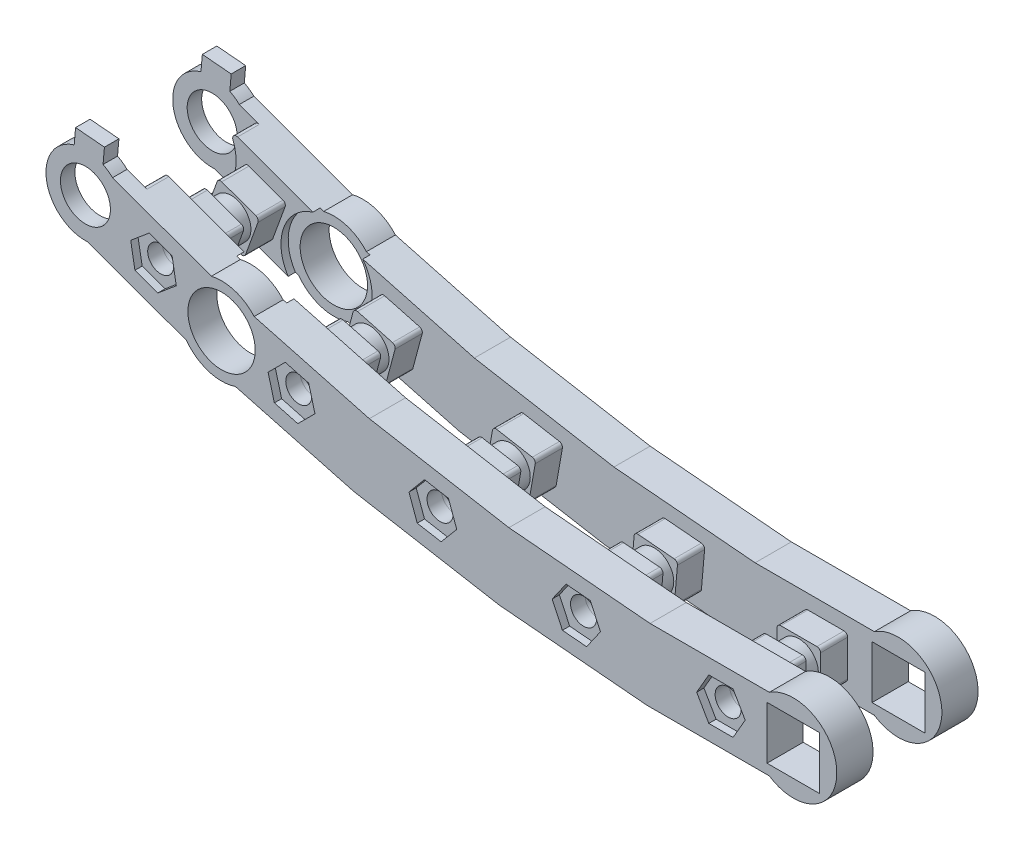
from build123d import *

# Parameters (mm, degrees)
SKETCH_1_R               = 1.8
SKETCH_1_R_2             = 3.45
SKETCH_1_W               = 7.28
SKETCH_1_H               = 7.28
EXTRUDE_1_DEPTH          = 2
SKETCH_2_R               = 1.8
SKETCH_2_W               = 7.28
SKETCH_2_H               = 7.28
EXTRUDE_2_DEPTH          = 3
EXTRUDE_3_DEPTH          = 2
SKETCH_4_R               = 1.8
SKETCH_4_R_2             = 3.45
SKETCH_4_W               = 7.28
SKETCH_4_H               = 7.28
EXTRUDE_4_DEPTH          = 2
SKETCH_5_R               = 1.8
SKETCH_5_W               = 7.28
SKETCH_5_H               = 7.28
EXTRUDE_5_DEPTH          = 3
EXTRUDE_6_DEPTH          = 2
SKETCH_7_W               = 6.2
SKETCH_7_H               = 6.2
CUT_EXTRUDE_1_DEPTH      = 2
SKETCH_8_W               = 6
SKETCH_8_H               = 6
SKETCH_8_R               = 1.8
EXTRUDE_7_DEPTH          = 11.5
SKETCH_9_R               = 2.7
SKETCH_9_W               = 6
SKETCH_9_H               = 6
CUT_EXTRUDE_2_DEPTH      = 1
CUT_EXTRUDE_2_DEPTH_BACK = 1
CUT_EXTRUDE_3_DEPTH      = 1
SKETCH_11_R              = 3.25
CUT_EXTRUDE_4_DEPTH      = 1.5
SKETCH_12_R              = 4.65
CUT_EXTRUDE_5_DEPTH      = 20.5
SKETCH_13_R              = 6.3
CUT_EXTRUDE_6_DEPTH      = 1
SKETCH_14_R              = 6.3
CUT_EXTRUDE_7_DEPTH      = 1
EXTRUDE_8_DEPTH          = 4
EXTRUDE_9_DEPTH          = 4
FILLET_1_R               = 0.5


with BuildPart() as part:
    # ｽｹｯﾁ1 → ﾎﾞｽ - 押し出し1 (new body)
    with BuildSketch(Plane.XY):
        with BuildLine():
            Line((-93.984570453, 21.189646103), (-77.433604161, 15.165587024))
            Line((-77.433604161, 15.165587024), (-58.536819958, 10.102208957))
            Line((-58.536819958, 10.102208957), (-39.270641249, 6.705061836))
            Line((-39.270641249, 6.705061836), (-19.781695285, 5))
            Line((-19.781695285, 5), (-3.31662479, 5))
            ThreePointArc((-3.31662479, 5), (6, 0), (-3.31662479, -5))
            Line((-3.31662479, -5), (-20.218304715, -5))
            Line((-20.218304715, -5), (-40.577146675, -3.218832126))
            Line((-40.577146675, -3.218832126), (-60.703278086, 0.329947859))
            Line((-60.703278086, 0.329947859), (-80.443526935, 5.619331597))
            Line((-80.443526935, 5.619331597), (-97.404771886, 11.792719895))
            ThreePointArc((-97.404771886, 11.792719895), (-102.853742747, 19.096871958), (-93.984570453, 21.189646103))
        make_face()
        with Locations((-10, 0)):
            Circle(SKETCH_1_R, mode=Mode.SUBTRACT)
        with Locations((-29.961946981, 0.871557427)):
            Circle(SKETCH_1_R, mode=Mode.SUBTRACT)
        with Locations((-49.771971492, 3.479596632)):
            Circle(SKETCH_1_R, mode=Mode.SUBTRACT)
        with Locations((-69.279307285, 7.804268859)):
            Circle(SKETCH_1_R, mode=Mode.SUBTRACT)
        with Locations((-88.335491756, 13.812660744)):
            Circle(SKETCH_1_R, mode=Mode.SUBTRACT)
        with Locations((-97.732417964, 17.232862177)):
            Circle(SKETCH_1_R_2, mode=Mode.SUBTRACT)
        Rectangle(SKETCH_1_W, SKETCH_1_H, mode=Mode.SUBTRACT)
    extrude(amount=EXTRUDE_1_DEPTH)

    # ｽｹｯﾁ2 → ﾎﾞｽ - 押し出し2 (add)
    with BuildSketch(Plane(origin=(0, 0, 0), x_dir=(-1, 0, 0), z_dir=(0, 0, -1))):
        with BuildLine():
            Line((91.23172777, 20.187693307), (77.433604161, 15.165587024))
            Line((77.433604161, 15.165587024), (58.536819958, 10.102208957))
            Line((58.536819958, 10.102208957), (39.270641249, 6.705061836))
            Line((39.270641249, 6.705061836), (19.781695285, 5))
            Line((19.781695285, 5), (3.31662479, 5))
            ThreePointArc((3.31662479, 5), (-6, 0), (3.31662479, -5))
            Line((3.31662479, -5), (20.218304715, -5))
            Line((20.218304715, -5), (40.577146675, -3.218832126))
            Line((40.577146675, -3.218832126), (60.703278086, 0.329947859))
            Line((60.703278086, 0.329947859), (80.443526935, 5.619331597))
            Line((80.443526935, 5.619331597), (94.651929203, 10.790767099))
            ThreePointArc((94.651929203, 10.790767099), (94.979522995, 11.223274587), (94.719999928, 11.699749348))
            ThreePointArc((94.719999928, 11.699749348), (91.812354453, 15.078135274), (91.868155498, 19.535127524))
            ThreePointArc((91.868155498, 19.535127524), (91.760689628, 20.066946579), (91.23172777, 20.187693307))
        make_face()
        with Locations((29.961946981, 0.871557427)):
            Circle(SKETCH_2_R, mode=Mode.SUBTRACT)
        with Locations((10, 0)):
            Circle(SKETCH_2_R, mode=Mode.SUBTRACT)
        with Locations((88.335491756, 13.812660744)):
            Circle(SKETCH_2_R, mode=Mode.SUBTRACT)
        with Locations((69.279307285, 7.804268859)):
            Circle(SKETCH_2_R, mode=Mode.SUBTRACT)
        with Locations((49.771971492, 3.479596632)):
            Circle(SKETCH_2_R, mode=Mode.SUBTRACT)
        Rectangle(SKETCH_2_W, SKETCH_2_H, mode=Mode.SUBTRACT)
    extrude(amount=EXTRUDE_2_DEPTH)

    # ｽｹｯﾁ3 → ﾎﾞｽ - 押し出し3 (add)
    with BuildSketch(Plane.XY.offset(2)):
        Polygon((-95.108149432, 24.280962253), (-95.421910106, 20.694661339), (-99.406688899, 21.04328431), (-99.092928225, 24.629585224), align=None)
    extrude(amount=-EXTRUDE_3_DEPTH)

    # ｽｹｯﾁ7 → ｶｯﾄ - 押し出し1 (cut)
    with BuildSketch(Plane(origin=(0, 0, -3), x_dir=(-1, 0, 0), z_dir=(0, 0, -1))):
        Polygon((27.143926219, -2.486828939), (26.603560614, 3.689578189), (32.779967742, 4.229943794), (33.320333348, -1.946463334), align=None)
        with Locations((10, 0)):
            Rectangle(SKETCH_7_W, SKETCH_7_H)
        Polygon((47.257376808, -0.111616753), (46.180758107, 5.994191315), (52.286566176, 7.070810017), (53.363184877, 0.965001948), align=None)
        Polygon((67.087276263, 4.007559758), (65.482598184, 9.996299881), (71.471338307, 11.600977961), (73.076016386, 5.612237838), align=None)
        Polygon((90.188276436, 17.785970312), (84.362182187, 15.665445424), (86.482707076, 9.839351175), (92.308801324, 11.959876063), align=None)
    extrude(amount=-CUT_EXTRUDE_1_DEPTH, mode=Mode.SUBTRACT)

    # ｽｹｯﾁ10 → ｶｯﾄ - 押し出し3 (cut)
    with BuildSketch(Plane.XY.offset(2)):
        Polygon((-11.674315781, 2.9), (-13.348631561, 0), (-11.674315781, -2.9), (-8.325684219, -2.9), (-6.651368439, 0), (-8.325684219, 2.9), align=None)
        Polygon((-31.882643139, -1.871480962), (-28.546754131, -2.163333432), (-26.626057974, 0.579704957), (-28.041250823, 3.614595816), (-31.377139831, 3.906448287), (-33.297835988, 1.163409898), align=None)
        Polygon((-51.924430369, 0.914396032), (-48.626672045, 0.332912264), (-46.474213168, 2.898112863), (-47.619512615, 6.044797231), (-50.917270938, 6.626281), (-53.069729816, 4.0610804), align=None)
        Polygon((-71.64714737, 5.436428775), (-68.412617662, 4.569739152), (-66.044777577, 6.937579236), (-66.9114672, 10.172108944), (-70.145996908, 11.038798567), (-72.513836993, 8.670958482), align=None)
        Polygon((-90.900692355, 11.660201867), (-87.754007987, 10.51490242), (-85.188807388, 12.667361297), (-85.770291156, 15.965119621), (-88.916975524, 17.110419067), (-91.482176124, 14.95796019), align=None)
    extrude(amount=-CUT_EXTRUDE_3_DEPTH, mode=Mode.SUBTRACT)


with BuildPart() as body_2:
    # ｽｹｯﾁ4 → ﾎﾞｽ - 押し出し4 (new body)
    with BuildSketch(Plane.XY.offset(-17.5)):
        with BuildLine():
            Line((-77.433604161, 15.165587024), (-93.984570453, 21.189646103))
            ThreePointArc((-93.984570453, 21.189646103), (-102.853742747, 19.096871958), (-97.404771886, 11.792719895))
            Line((-97.404771886, 11.792719895), (-80.443526935, 5.619331597))
            Line((-80.443526935, 5.619331597), (-60.703278086, 0.329947859))
            Line((-60.703278086, 0.329947859), (-40.577146675, -3.218832126))
            Line((-40.577146675, -3.218832126), (-20.218304715, -5))
            Line((-20.218304715, -5), (-3.31662479, -5))
            ThreePointArc((-3.31662479, -5), (6, 0), (-3.31662479, 5))
            Line((-3.31662479, 5), (-19.781695285, 5))
            Line((-19.781695285, 5), (-39.270641249, 6.705061836))
            Line((-39.270641249, 6.705061836), (-58.536819958, 10.102208957))
            Line((-58.536819958, 10.102208957), (-77.433604161, 15.165587024))
        make_face()
        with Locations((-29.961946981, 0.871557427)):
            Circle(SKETCH_4_R, mode=Mode.SUBTRACT)
        with Locations((-10, 0)):
            Circle(SKETCH_4_R, mode=Mode.SUBTRACT)
        with Locations((-97.732417964, 17.232862177)):
            Circle(SKETCH_4_R_2, mode=Mode.SUBTRACT)
        with Locations((-88.335491756, 13.812660744)):
            Circle(SKETCH_4_R, mode=Mode.SUBTRACT)
        with Locations((-69.279307285, 7.804268859)):
            Circle(SKETCH_4_R, mode=Mode.SUBTRACT)
        with Locations((-49.771971492, 3.479596632)):
            Circle(SKETCH_4_R, mode=Mode.SUBTRACT)
        Rectangle(SKETCH_4_W, SKETCH_4_H, mode=Mode.SUBTRACT)
    extrude(amount=EXTRUDE_4_DEPTH)

    # ｽｹｯﾁ5 → ﾎﾞｽ - 押し出し5 (add)
    with BuildSketch(Plane.XY.offset(-15.5)):
        with BuildLine():
            Line((-80.443526935, 5.619331597), (-60.703278086, 0.329947859))
            Line((-60.703278086, 0.329947859), (-40.577146675, -3.218832126))
            Line((-40.577146675, -3.218832126), (-20.218304715, -5))
            Line((-20.218304715, -5), (-3.31662479, -5))
            ThreePointArc((-3.31662479, -5), (6, 0), (-3.31662479, 5))
            Line((-3.31662479, 5), (-19.781695285, 5))
            Line((-19.781695285, 5), (-39.270641249, 6.705061836))
            Line((-39.270641249, 6.705061836), (-58.536819958, 10.102208957))
            Line((-58.536819958, 10.102208957), (-77.433604161, 15.165587024))
            Line((-77.433604161, 15.165587024), (-91.23172777, 20.187693307))
            ThreePointArc((-91.23172777, 20.187693307), (-91.760689628, 20.066946579), (-91.868155498, 19.535127524))
            ThreePointArc((-91.868155498, 19.535127524), (-91.812354453, 15.078135274), (-94.719999928, 11.699749348))
            ThreePointArc((-94.719999928, 11.699749348), (-94.979522995, 11.223274587), (-94.651929203, 10.790767099))
            Line((-94.651929203, 10.790767099), (-80.443526935, 5.619331597))
        make_face()
        with Locations((-10, 0)):
            Circle(SKETCH_5_R, mode=Mode.SUBTRACT)
        with Locations((-29.961946981, 0.871557427)):
            Circle(SKETCH_5_R, mode=Mode.SUBTRACT)
        with Locations((-49.771971492, 3.479596632)):
            Circle(SKETCH_5_R, mode=Mode.SUBTRACT)
        with Locations((-69.279307285, 7.804268859)):
            Circle(SKETCH_5_R, mode=Mode.SUBTRACT)
        with Locations((-88.335491756, 13.812660744)):
            Circle(SKETCH_5_R, mode=Mode.SUBTRACT)
        Rectangle(SKETCH_5_W, SKETCH_5_H, mode=Mode.SUBTRACT)
    extrude(amount=EXTRUDE_5_DEPTH)

    # ｽｹｯﾁ6 → ﾎﾞｽ - 押し出し6 (add)
    with BuildSketch(Plane(origin=(0, 0, -17.5), x_dir=(-1, 0, 0), z_dir=(0, 0, -1))):
        Polygon((95.108149432, 24.280962253), (95.421910106, 20.694661339), (99.406688899, 21.04328431), (99.092928225, 24.629585224), align=None)
    extrude(amount=-EXTRUDE_6_DEPTH)

    # ｽｹｯﾁ8 → ﾎﾞｽ - 押し出し7 (add)
    with BuildSketch(Plane.XY.offset(-12.5)):
        with Locations((-10, 0)):
            Rectangle(SKETCH_8_W, SKETCH_8_H)
        with Locations((-10, 0)):
            Circle(SKETCH_8_R, mode=Mode.SUBTRACT)
        Polygon((-27.234830115, -2.378493895), (-26.711895658, 3.598674294), (-32.689063847, 4.12160875), (-33.211998303, -1.855559439), align=None)
        with Locations((-29.961946981, 0.871557427)):
            Circle(SKETCH_8_R, mode=Mode.SUBTRACT)
        Polygon((-84.490353463, 15.605678176), (-90.128509188, 17.657799036), (-92.180630048, 12.019643311), (-86.542474323, 9.967522451), align=None)
        with Locations((-88.335491756, 13.812660744)):
            Circle(SKETCH_8_R, mode=Mode.SUBTRACT)
        Polygon((-67.157986941, 4.130034245), (-65.605072671, 9.925589203), (-71.400627629, 11.478503473), (-72.953541899, 5.682948516), align=None)
        with Locations((-69.279307285, 7.804268859)):
            Circle(SKETCH_8_R, mode=Mode.SUBTRACT)
        Polygon((-47.338492766, 0.00422884), (-46.2966037, 5.913075358), (-52.205450218, 6.954964424), (-53.247339284, 1.046117906), align=None)
        with Locations((-49.771971492, 3.479596632)):
            Circle(SKETCH_8_R, mode=Mode.SUBTRACT)
    extrude(amount=EXTRUDE_7_DEPTH)

    # ｽｹｯﾁ9 → ｶｯﾄ - 押し出し2 (cut, two sides)
    with BuildSketch(Plane.XY.offset(-7.75)) as cut_extrude_2_sk:
        Polygon((-84.490353463, 15.605678176), (-90.128509188, 17.657799036), (-92.180630048, 12.019643311), (-86.542474323, 9.967522451), align=None)
        with Locations((-88.335491756, 13.812660744)):
            Circle(SKETCH_9_R, mode=Mode.SUBTRACT)
        Polygon((-27.234830115, -2.378493895), (-26.711895658, 3.598674294), (-32.689063847, 4.12160875), (-33.211998303, -1.855559439), align=None)
        with Locations((-29.961946981, 0.871557427)):
            Circle(SKETCH_9_R, mode=Mode.SUBTRACT)
        with Locations((-10, 0)):
            Rectangle(SKETCH_9_W, SKETCH_9_H)
        with Locations((-10, 0)):
            Circle(SKETCH_9_R, mode=Mode.SUBTRACT)
        Polygon((-47.338492766, 0.00422884), (-46.2966037, 5.913075358), (-52.205450218, 6.954964424), (-53.247339284, 1.046117906), align=None)
        with Locations((-49.771971492, 3.479596632)):
            Circle(SKETCH_9_R, mode=Mode.SUBTRACT)
        Polygon((-67.157986941, 4.130034245), (-65.605072671, 9.925589203), (-71.400627629, 11.478503473), (-72.953541899, 5.682948516), align=None)
        with Locations((-69.279307285, 7.804268859)):
            Circle(SKETCH_9_R, mode=Mode.SUBTRACT)
    extrude(amount=CUT_EXTRUDE_2_DEPTH, mode=Mode.SUBTRACT)
    extrude(cut_extrude_2_sk.sketch, amount=-CUT_EXTRUDE_2_DEPTH_BACK, mode=Mode.SUBTRACT)

    # ｽｹｯﾁ11 → ｶｯﾄ - 押し出し4 (cut)
    with BuildSketch(Plane(origin=(0, 0, -17.5), x_dir=(-1, 0, 0), z_dir=(0, 0, -1))):
        with Locations((10, 0)):
            Circle(SKETCH_11_R)
        with Locations((29.961946981, 0.871557427)):
            Circle(SKETCH_11_R)
        with Locations((49.771971492, 3.479596632)):
            Circle(SKETCH_11_R)
        with Locations((69.279307285, 7.804268859)):
            Circle(SKETCH_11_R)
        with Locations((88.335491756, 13.812660744)):
            Circle(SKETCH_11_R)
    extrude(amount=-CUT_EXTRUDE_4_DEPTH, mode=Mode.SUBTRACT)


with BuildPart() as cut_extrude_5_tool:
    # ｽｹｯﾁ12 → ｶｯﾄ - 押し出し5 (new body, through all)
    with BuildSketch(Plane.XY.offset(2)):
        with Locations((-78.938565548, 10.39245931)):
            Circle(SKETCH_12_R)
    extrude(amount=-CUT_EXTRUDE_5_DEPTH)


with BuildPart() as part_1:
    add(part.part)

    # ｶｯﾄ - 押し出し5: cut by cut_extrude_5_tool
    add(cut_extrude_5_tool.part, mode=Mode.SUBTRACT)

    # ｽｹｯﾁ13 → ｶｯﾄ - 押し出し6 (cut)
    with BuildSketch(Plane(origin=(0, 0, -3), x_dir=(-1, 0, 0), z_dir=(0, 0, -1))):
        with Locations((78.938565548, 10.39245931)):
            Circle(SKETCH_13_R)
    extrude(amount=-CUT_EXTRUDE_6_DEPTH, mode=Mode.SUBTRACT)

    # ｽｹｯﾁ15 → ﾎﾞｽ - 押し出し8 (add)
    with BuildSketch(Plane(origin=(0, 0, -2), x_dir=(-1, 0, 0), z_dir=(0, 0, -1))):
        with BuildLine():
            Line((74.440856781, 14.363682781), (77.433604161, 15.165587024))
            Line((77.433604161, 15.165587024), (80.345072673, 16.2252749))
            ThreePointArc((80.345072673, 16.2252749), (77.134330751, 16.114761015), (74.440856781, 14.363682781))
        make_face()
        with BuildLine():
            Line((77.029047232, 4.704424518), (80.443526935, 5.619331597))
            Line((80.443526935, 5.619331597), (83.765274106, 6.828348693))
            ThreePointArc((83.765274106, 6.828348693), (80.742800345, 4.670157606), (77.029047232, 4.704424518))
        make_face()
    extrude(amount=-EXTRUDE_8_DEPTH)


with BuildPart() as body_2_1:
    add(body_2.part)

    # ｶｯﾄ - 押し出し5: cut by cut_extrude_5_tool
    add(cut_extrude_5_tool.part, mode=Mode.SUBTRACT)

    # ｽｹｯﾁ14 → ｶｯﾄ - 押し出し7 (cut)
    with BuildSketch(Plane.XY.offset(-12.5)):
        with Locations((-78.938565548, 10.39245931)):
            Circle(SKETCH_14_R)
    extrude(amount=-CUT_EXTRUDE_7_DEPTH, mode=Mode.SUBTRACT)

    # ｽｹｯﾁ16 → ﾎﾞｽ - 押し出し9 (add)
    with BuildSketch(Plane.XY.offset(-13.5)):
        with BuildLine():
            Line((-77.029047232, 4.704424518), (-80.443526935, 5.619331597))
            Line((-80.443526935, 5.619331597), (-83.765274106, 6.828348693))
            ThreePointArc((-83.765274106, 6.828348693), (-80.742800345, 4.670157606), (-77.029047232, 4.704424518))
        make_face()
        with BuildLine():
            Line((-77.433604161, 15.165587024), (-74.440856781, 14.363682781))
            ThreePointArc((-74.440856781, 14.363682781), (-77.134330751, 16.114761015), (-80.345072673, 16.2252749))
            Line((-80.345072673, 16.2252749), (-77.433604161, 15.165587024))
        make_face()
    extrude(amount=-EXTRUDE_9_DEPTH)

    # ﾌｨﾚｯﾄ1
    fillet_1_edges = [body_2_1.edges().sort_by_distance(p)[0] for p in [
        (-7, 3, -3.875),
        (-7, -3, -3.875),
        (-13, -3, -3.875),
        (-13, 3, -3.875),
        (-32.689063847, 4.12160875, -3.875),
        (-26.711895658, 3.598674294, -3.875),
        (-27.234830115, -2.378493895, -3.875),
        (-33.211998303, -1.855559439, -3.875),
        (-92.180630048, 12.019643311, -3.875),
        (-90.128509188, 17.657799036, -3.875),
        (-84.490353463, 15.605678176, -3.875),
        (-86.542474323, 9.967522451, -3.875),
        (-71.400627629, 11.478503473, -3.875),
        (-65.605072671, 9.925589203, -3.875),
        (-67.157986941, 4.130034245, -3.875),
        (-72.953541899, 5.682948516, -3.875),
        (-52.205450218, 6.954964424, -3.875),
        (-46.2966037, 5.913075358, -3.875),
        (-47.338492766, 0.00422884, -3.875),
        (-53.247339284, 1.046117906, -3.875),
        (-53.247339284, 1.046117906, -10.625),
        (-47.338492766, 0.00422884, -10.625),
        (-46.2966037, 5.913075358, -10.625),
        (-52.205450218, 6.954964424, -10.625),
        (-72.953541899, 5.682948516, -10.625),
        (-67.157986941, 4.130034245, -10.625),
        (-65.605072671, 9.925589203, -10.625),
        (-71.400627629, 11.478503473, -10.625),
        (-86.542474323, 9.967522451, -10.625),
        (-84.490353463, 15.605678176, -10.625),
        (-90.128509188, 17.657799036, -10.625),
        (-92.180630048, 12.019643311, -10.625),
        (-33.211998303, -1.855559439, -10.625),
        (-27.234830115, -2.378493895, -10.625),
        (-26.711895658, 3.598674294, -10.625),
        (-32.689063847, 4.12160875, -10.625),
        (-13, 3, -10.625),
        (-13, -3, -10.625),
        (-7, -3, -10.625),
        (-7, 3, -10.625),
    ]]
    fillet(fillet_1_edges, radius=FILLET_1_R)


solid = Compound([part_1.part, body_2_1.part])
